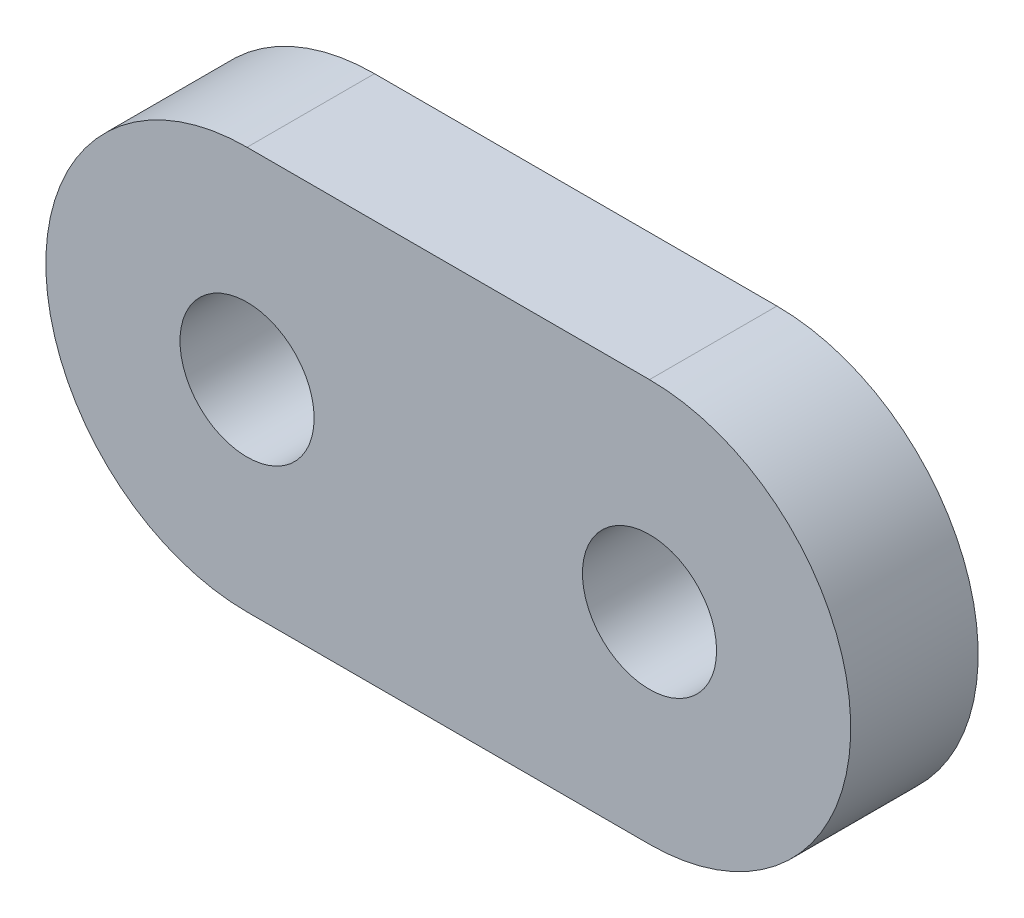
from build123d import *

# Parameters (mm, degrees)
SKETCH_1_R      = 1
EXTRUDE_1_DEPTH = 1.9


with BuildPart() as part:
    # 草图1 → 凸台-拉伸1 (new body)
    with BuildSketch(Plane.XY):
        with BuildLine():
            Line((0, -3), (6, -3))
            ThreePointArc((6, -3), (8.999999499, -5.01e-07), (6, 2.999999499))
            Line((6, 2.999999499), (0, 2.999999499))
            ThreePointArc((0, 2.999999499), (-2.999999499, 0), (0, -3))
        make_face()
        Circle(SKETCH_1_R, mode=Mode.SUBTRACT)
        with Locations((6, -5.01e-07)):
            Circle(SKETCH_1_R, mode=Mode.SUBTRACT)
    extrude(amount=EXTRUDE_1_DEPTH)


solid = part.part
